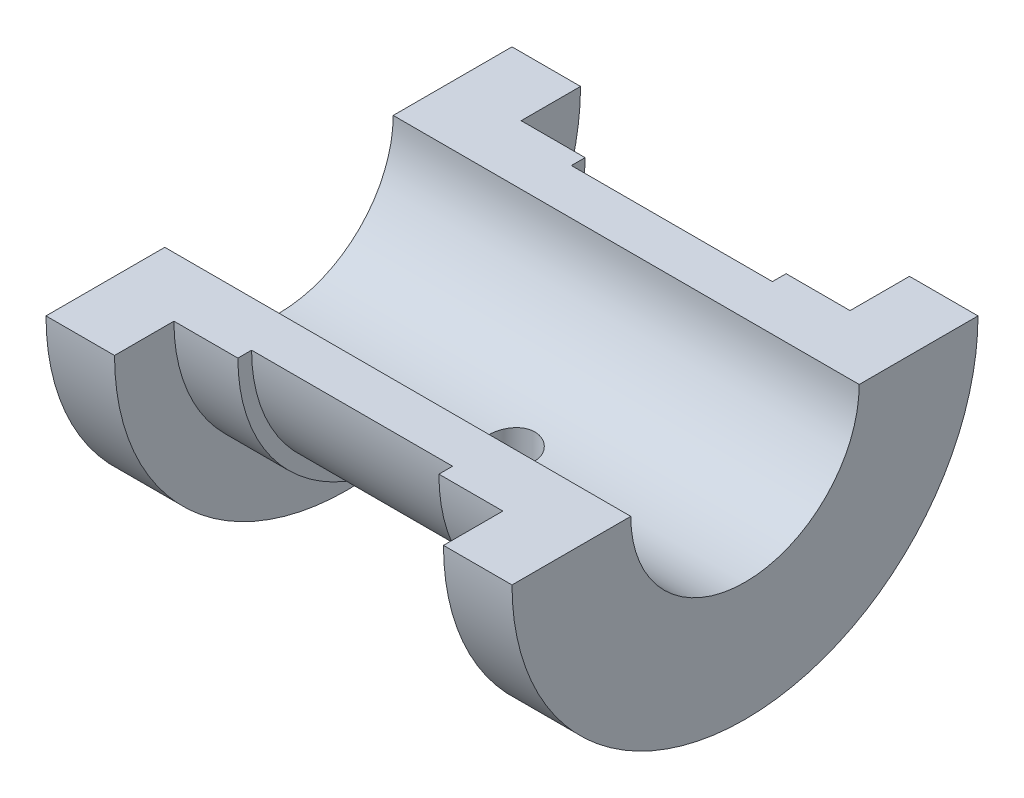
from build123d import *

# Parameters (mm, degrees)
REVOLVE3_ANGLE           = 180
CUT_EXTRUDE1_DEPTH       = 52
F_6_0_6_DIAMETER_HOLE1_D = 5


with BuildPart() as part:
    # Sketch2 → Revolve3 (revolve)
    with BuildSketch(Plane(origin=(0, 0, 0), x_dir=(1, 0, 0), z_dir=(0, 1, 0))):
        Polygon((25.5, 0), (-25.5, 0), (-25.5, 25.5), (-18, 25.5), (-18, 19), (-11, 19), (-11, 17.5), (11, 17.5), (11, 19), (18, 19), (18, 25.5), (25.5, 25.5), align=None)
    revolve(axis=Axis((25.5, 0, 0), (-1, 0, 0)), revolution_arc=REVOLVE3_ANGLE)

    # Sketch3 → Cut-Extrude1 (cut, through all)
    with BuildSketch(Plane.ZY.offset(25.5)):
        with BuildLine():
            Line((12.5, 0), (-12.5, 0))
            ThreePointArc((-12.5, 0), (0, -12.5), (12.5, 0))
        make_face()
    extrude(amount=-CUT_EXTRUDE1_DEPTH, mode=Mode.SUBTRACT)

    # Ø6.0 (6) Diameter Hole1 (through all)
    with Locations(Plane(origin=(0, -17.5, 0), x_dir=(0, 0, -1), z_dir=(0, -1, 0))):
        with Locations((0, 0)):
            Hole(F_6_0_6_DIAMETER_HOLE1_D / 2)


solid = part.part
